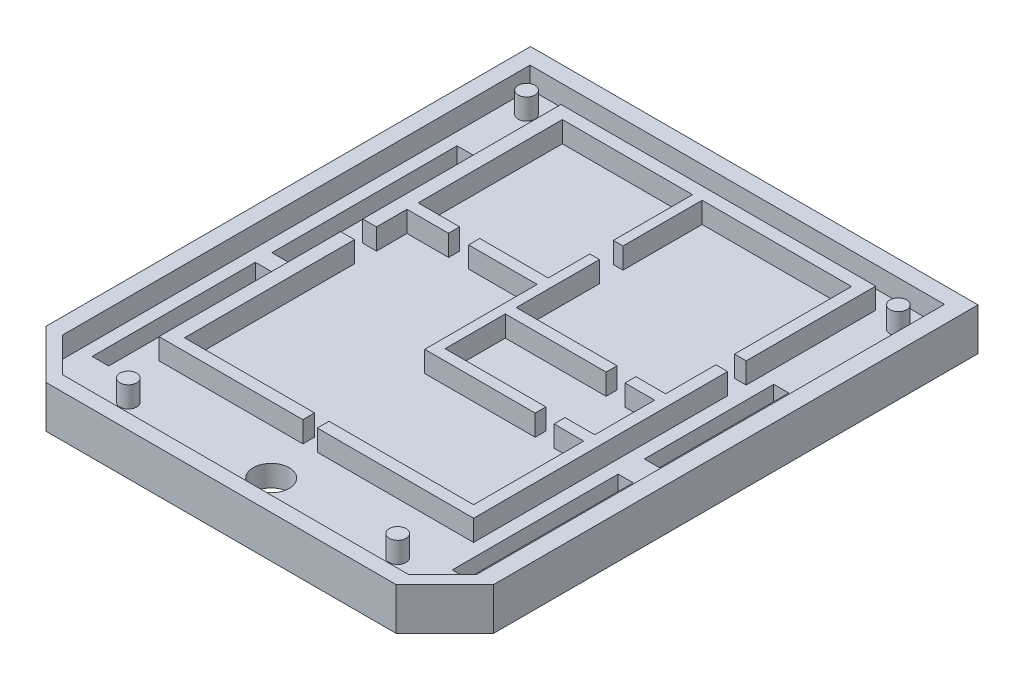
from build123d import *

# Parameters (mm, degrees)
BOSS_EXTRUDE1_DEPTH = 2.015360823
CUT_EXTRUDE4_DEPTH  = 1
SKETCH14_W          = 0.787440713
SKETCH14_H          = 8.825897992
SKETCH14_H_2        = 7.775977042
SKETCH14_W_2        = 0.721820654
SKETCH14_H_3        = 6.168285585
SKETCH14_H_4        = 7.907217161
CUT_EXTRUDE8_DEPTH  = 2
SKETCH16_R          = 0.858720655
CUT_EXTRUDE9_DEPTH  = 2
SKETCH17_W          = 1.980286876
SKETCH17_H          = 0.530178386
SKETCH17_W_2        = 0.459340416
SKETCH17_H_2        = 3.773153417
SKETCH17_W_3        = 1.417450885
SKETCH17_H_3        = 0.52338797
SKETCH17_H_4        = 0.521784595
SKETCH17_W_4        = 3.263347093
BOSS_EXTRUDE5_DEPTH = 1
SKETCH18_R          = 0.400497452
BOSS_EXTRUDE6_DEPTH = 1


with BuildPart() as part:
    # Sketch1 → Boss-Extrude1 (new body)
    with BuildSketch(Plane(origin=(0, 0, 0), x_dir=(1, 0, 0), z_dir=(0, 1, 0))):
        Polygon((-24.716746523, 29.689845928), (-24.716746523, 27.490492708), (-24.716746523, 6.596637121), (-22.39957081, 4.279461407), (-5.708050839, 4.279461407), (-3.390875125, 6.596637121), (-3.390875125, 29.689845928), align=None)
    extrude(amount=BOSS_EXTRUDE1_DEPTH)

    # Sketch13 → Cut-Extrude4 (cut)
    with BuildSketch(Plane(origin=(0, 2.015360823, 0), x_dir=(1, 0, 0), z_dir=(0, 1, 0))):
        Polygon((-23.962439797, 28.911099467), (-23.962439797, 6.633089294), (-22.321938311, 4.992587808), (-5.851303397, 4.992587808), (-4.210801911, 6.633089294), (-4.210801911, 28.911099467), align=None)
    extrude(amount=-CUT_EXTRUDE4_DEPTH, mode=Mode.SUBTRACT)

    # Sketch14 → Cut-Extrude8 (cut)
    with BuildSketch(Plane(origin=(0, 1.015360823, 0), x_dir=(1, 0, 0), z_dir=(0, 1, 0))):
        with Locations((-22.978138906, 20.429706787)):
            Rectangle(SKETCH14_W, SKETCH14_H)
        with Locations((-22.978138906, 11.341328557)):
            Rectangle(SKETCH14_W, SKETCH14_H_2)
        with Locations((-5.621633189, 19.461810911)):
            Rectangle(SKETCH14_W_2, SKETCH14_H_3)
        with Locations((-5.621633189, 11.177278409)):
            Rectangle(SKETCH14_W_2, SKETCH14_H_4)
    extrude(amount=-CUT_EXTRUDE8_DEPTH, mode=Mode.SUBTRACT)

    # Sketch16 → Cut-Extrude9 (cut)
    with BuildSketch(Plane(origin=(0, 1.015360823, 0), x_dir=(1, 0, 0), z_dir=(0, 1, 0))):
        with Locations((-14.086620854, 6.698709353)):
            Circle(SKETCH16_R)
    extrude(amount=-CUT_EXTRUDE9_DEPTH, mode=Mode.SUBTRACT)

    # Sketch17 → Boss-Extrude5 (add)
    with BuildSketch(Plane(origin=(0, 1.015360823, 0), x_dir=(1, 0, 0), z_dir=(0, 1, 0))):
        Polygon((-6.60593408, 28.025228665), (-21.600117658, 28.025228665), (-21.600117658, 18.575940108), (-20.943917063, 18.575940108), (-20.943917063, 20.028920156), (-20.943917063, 20.559098542), (-20.943917063, 27.43464813), (-14.742821448, 27.43464813), (-14.283481032, 27.43464813), (-7.163704585, 27.43464813), (-7.163704585, 21.856943079), (-6.60593408, 21.856943079), align=None)
        with Locations((-19.953773625, 20.294009349)):
            Rectangle(SKETCH17_W, SKETCH17_H)
        with Locations((-14.51315124, 25.548071422)):
            Rectangle(SKETCH17_W_2, SKETCH17_H_2)
        Polygon((-20.943917063, 17.526019157), (-21.600117658, 17.526019157), (-21.600117658, 8.864171314), (-14.742821448, 8.864171314), (-14.742821448, 9.421941819), (-20.943917063, 9.421941819), align=None)
        Polygon((-7.163704585, 9.421941819), (-14.053810824, 9.421941819), (-14.053810824, 8.864171314), (-6.60593408, 8.864171314), (-6.60593408, 20.971072277), (-7.163704585, 20.971072277), (-7.163704585, 18.575940108), (-7.163704585, 18.054155513), (-7.163704585, 15.196507048), (-7.163704585, 14.673119078), align=None)
        with Locations((-7.872430028, 14.934813063)):
            Rectangle(SKETCH17_W_3, SKETCH17_H_3)
        with Locations((-7.872430028, 18.315047811)):
            Rectangle(SKETCH17_W_3, SKETCH17_H_4)
        Polygon((-14.283481032, 22.542256975), (-14.742821448, 22.542256975), (-14.742821448, 20.559098542), (-14.742821448, 20.028920156), (-14.742821448, 18.054155513), (-14.283481032, 18.054155513), (-9.478775763, 18.054155513), (-9.478775763, 18.575940108), (-14.283481032, 18.575940108), align=None)
        with Locations((-16.374494995, 20.294009349)):
            Rectangle(SKETCH17_W_4, SKETCH17_H)
        Polygon((-14.283481032, 18.054155513), (-14.742821448, 18.054155513), (-14.742821448, 14.673119078), (-9.478775763, 14.673119078), (-9.478775763, 15.181770577), (-14.283481032, 15.181770577), align=None)
    extrude(amount=BOSS_EXTRUDE5_DEPTH)

    # Sketch18 → Boss-Extrude6 (add)
    with BuildSketch(Plane(origin=(0, 1.015360823, 0), x_dir=(1, 0, 0), z_dir=(0, 1, 0))):
        with Locations((-23.010948935, 27.795558457)):
            Circle(SKETCH18_R)
        with Locations((-20.622593862, 6.426229891)):
            Circle(SKETCH18_R)
        with Locations((-5.293532892, 27.795558457)):
            Circle(SKETCH18_R)
        with Locations((-7.78709515, 6.426229891)):
            Circle(SKETCH18_R)
    extrude(amount=BOSS_EXTRUDE6_DEPTH)


solid = part.part
